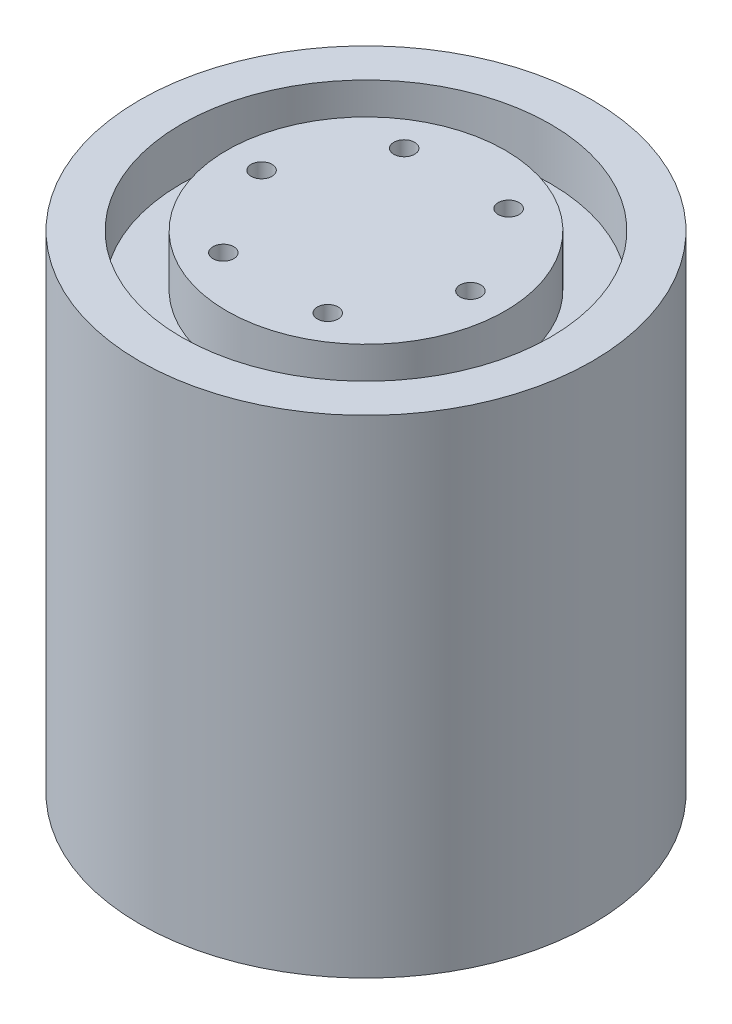
from build123d import *

# Parameters (mm, degrees)
CROQUIS1_R              = 32.5
SALIENTE_EXTRUIR1_DEPTH = 70
CROQUIS2_R              = 1.5
CORTAR_EXTRUIR1_DEPTH   = 5
CROQUIS2_3_R            = 26.5
CROQUIS2_3_R_2          = 20
CORTAR_EXTRUIR2_DEPTH   = 7.4


with BuildPart() as part:
    # Croquis1 → Saliente-Extruir1 (new body)
    with BuildSketch(Plane(origin=(0, 0, 0), x_dir=(1, 0, 0), z_dir=(0, 1, 0))):
        Circle(CROQUIS1_R)
    extrude(amount=SALIENTE_EXTRUIR1_DEPTH)

    # Croquis2 → Cortar-Extruir1 (cut)
    with BuildSketch(Plane(origin=(0, 70, 0), x_dir=(1, 0, 0), z_dir=(0, 1, 0))):
        with Locations((15, 0)):
            Circle(CROQUIS2_R)
        with Locations((7.5, -12.990381057)):
            Circle(CROQUIS2_R)
        with Locations((-7.5, -12.990381057)):
            Circle(CROQUIS2_R)
        with Locations((-15, 0)):
            Circle(CROQUIS2_R)
        with Locations((-7.5, 12.990381057)):
            Circle(CROQUIS2_R)
        with Locations((7.5, 12.990381057)):
            Circle(CROQUIS2_R)
    extrude(amount=-CORTAR_EXTRUIR1_DEPTH, mode=Mode.SUBTRACT)

    # Croquis2_3 → Cortar-Extruir2 (cut)
    with BuildSketch(Plane(origin=(0, 70, 0), x_dir=(1, 0, 0), z_dir=(0, 1, 0))):
        Circle(CROQUIS2_3_R)
        Circle(CROQUIS2_3_R_2, mode=Mode.SUBTRACT)
    extrude(amount=-CORTAR_EXTRUIR2_DEPTH, mode=Mode.SUBTRACT)


solid = part.part
